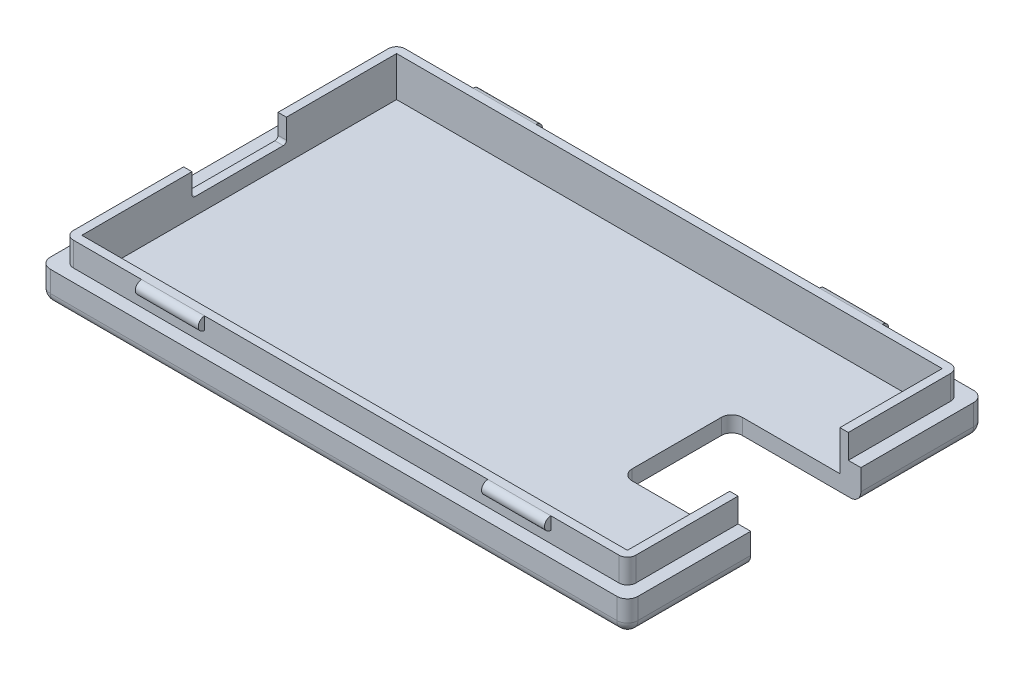
from build123d import *

# Parameters (mm, degrees)
SKETCH1_W             = 56
SKETCH1_H             = 34
BASE_DEPTH            = 1.5
SKETCH1_3_W           = 56
SKETCH1_3_H           = 34
SKETCH1_3_W_2         = 52
SKETCH1_3_H_2         = 30
BOSS_EXTRUDE2_DEPTH   = 3
SKETCH2_W             = 53.6
SKETCH2_H             = 31.6
SKETCH2_W_2           = 52
SKETCH2_H_2           = 30
WALL_DEPTH            = 2.3
SKETCH3_W             = 1.2
SKETCH3_H             = 3.75
GROOVEFOROPEN_DEPTH   = 1
LOCKPINS_START        = 13.5
SKETCH4_R             = 0.6
LOCKPINS_DEPTH        = 6
FILLETBASE_R          = 1
FILLETINNER_R         = 0.8
CUTCABLE_DEPTH        = 34.182676203
CUTFORCONNECTOR_DEPTH = 34.182676203


with BuildPart() as part:
    # Sketch1 → Base (new body)
    with BuildSketch(Plane(origin=(0, 0, 0), x_dir=(1, 0, 0), z_dir=(0, 1, 0))):
        Rectangle(SKETCH1_W, SKETCH1_H)
    extrude(amount=BASE_DEPTH)

    # Sketch1_3 → Boss-Extrude2 (add)
    with BuildSketch(Plane(origin=(0, 0, 0), x_dir=(1, 0, 0), z_dir=(0, 1, 0))):
        Rectangle(SKETCH1_3_W, SKETCH1_3_H)
        Rectangle(SKETCH1_3_W_2, SKETCH1_3_H_2, mode=Mode.SUBTRACT)
    extrude(amount=BOSS_EXTRUDE2_DEPTH)

    # Sketch2 → Wall (add)
    with BuildSketch(Plane(origin=(0, 3, 0), x_dir=(1, 0, 0), z_dir=(0, 1, 0))):
        Rectangle(SKETCH2_W, SKETCH2_H)
        Rectangle(SKETCH2_W_2, SKETCH2_H_2, mode=Mode.SUBTRACT)
    extrude(amount=WALL_DEPTH)

    # Sketch3 → GrooveForOpen (cut)
    with BuildSketch(Plane(origin=(0, 3, 0), x_dir=(1, 0, 0), z_dir=(0, 1, 0))):
        with Locations((-27.4, -8.375)):
            Rectangle(SKETCH3_W, SKETCH3_H)
        with Locations((-27.4, 8.375)):
            Rectangle(SKETCH3_W, SKETCH3_H)
    extrude(amount=-GROOVEFOROPEN_DEPTH, mode=Mode.SUBTRACT)

    # Sketch4 → LockPins (add)
    with BuildSketch(Plane(origin=(0, 0, 0), x_dir=(0, 0, -1), z_dir=(1, 0, 0)).offset(LOCKPINS_START)):
        with Locations((15.8, 4.7)):
            Circle(SKETCH4_R)
        with Locations((-15.8, 4.7)):
            Circle(SKETCH4_R)
    lockpins = extrude(amount=LOCKPINS_DEPTH)

    # LockPins2: LockPins across plane
    add(lockpins.mirror(Plane(origin=(0, 0, 0), x_dir=(0, 0, 1), z_dir=(1, 0, 0))))

    # FilletBase
    filletbase_edges = [part.edges().sort_by_distance(p)[0] for p in [
        (0, 0, 17),
        (28, 0, 0),
        (0, 0, -17),
        (-28, 0, 0),
        (28, 1.5, 17),
        (-28, 1.5, 17),
        (-28, 1.5, -17),
        (28, 1.5, -17),
    ]]
    fillet(filletbase_edges, radius=FILLETBASE_R)

    # FilletInner
    filletinner_edges = [part.edges().sort_by_distance(p)[0] for p in [
        (26.8, 4.15, 15.8),
        (-26.8, 4.15, 15.8),
        (-26.8, 4.15, -15.8),
        (26.8, 4.15, -15.8),
    ]]
    fillet(filletinner_edges, radius=FILLETINNER_R)

    # Sketch5 → CutCable (cut, through all)
    with BuildSketch(Plane(origin=(0, 0, 0), x_dir=(0, 0, -1), z_dir=(1, 0, 0))):
        with BuildLine():
            Line((-4.5, 5.462258994), (4.5, 5.462258994))
            Line((4.5, 5.462258994), (4.5, 3.4))
            ThreePointArc((4.5, 3.4), (4.412132034, 3.187867966), (4.2, 3.1))
            Line((4.2, 3.1), (-4.2, 3.1))
            ThreePointArc((-4.2, 3.1), (-4.412132034, 3.187867966), (-4.5, 3.4))
            Line((-4.5, 3.4), (-4.5, 5.462258994))
        make_face()
    extrude(amount=-CUTCABLE_DEPTH, mode=Mode.SUBTRACT)

    # Sketch7 → CutForConnector (cut, through all)
    with BuildSketch(Plane.XZ):
        with BuildLine():
            Line((28.0151422, -5.25), (16.7, -5.25))
            ThreePointArc((16.7, -5.25), (15.992893219, -4.957106781), (15.7, -4.25))
            Line((15.7, -4.25), (15.7, 4.25))
            ThreePointArc((15.7, 4.25), (15.992893219, 4.957106781), (16.7, 5.25))
            Line((16.7, 5.25), (28.0151422, 5.25))
            Line((28.0151422, 5.25), (28.0151422, -5.25))
        make_face()
    extrude(amount=-CUTFORCONNECTOR_DEPTH, mode=Mode.SUBTRACT)


solid = part.part
